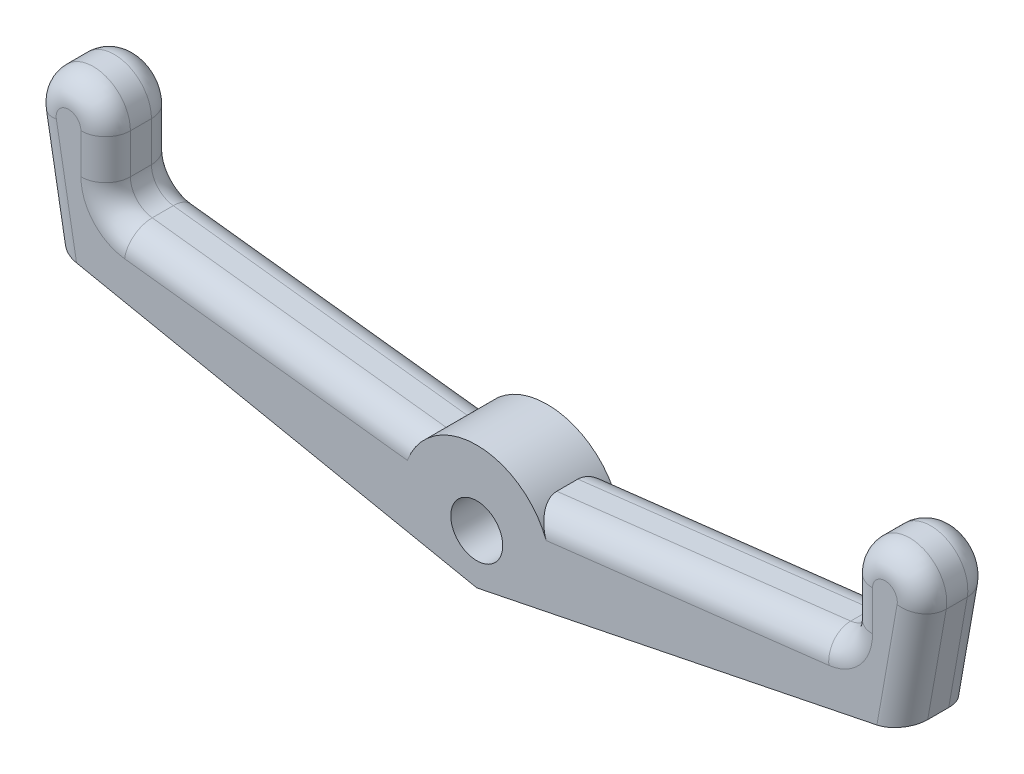
from build123d import *

# Parameters (mm, degrees)
SKETCH1_R           = 1.05
BOSS_EXTRUDE1_DEPTH = 2.85
FILLET2_R           = 1
FILLET1_R           = 1


with BuildPart() as part:
    # Sketch1 → Boss-Extrude1 (new body)
    with BuildSketch(Plane.XY):
        with BuildLine():
            Line((2.236067977, 2), (15, 3.5))
            Line((15, 3.5), (15, 6))
            ThreePointArc((15, 6), (16.630733614, 7.494292047), (17.97721163, 5.739527733))
            Line((17.97721163, 5.739527733), (17.229668505, 1.5))
            Line((17.229668505, 1.5), (0, -2))
            Line((0, -2), (-17.229668505, 1.5))
            Line((-17.229668505, 1.5), (-17.97721163, 5.739527733))
            ThreePointArc((-17.97721163, 5.739527733), (-16.630733614, 7.494292047), (-15, 6))
            Line((-15, 6), (-15, 3.5))
            Line((-15, 3.5), (-2.236067977, 2))
            ThreePointArc((-2.236067977, 2), (0, 3), (2.236067977, 2))
        make_face()
        Circle(SKETCH1_R, mode=Mode.SUBTRACT)
    extrude(amount=BOSS_EXTRUDE1_DEPTH)

    # Fillet2
    fillet2_edges = [part.edges().sort_by_distance(p)[0] for p in [
        (15, 3.5, 1.425),
        (-15, 3.5, 1.425),
    ]]
    fillet(fillet2_edges, radius=FILLET2_R)

    # Fillet1
    fillet1_edges = [part.edges().sort_by_distance(p)[0] for p in [
        (15, 5.194681496, 0),
        (16.630733614, 7.494292047, 0),
        (17.603440067, 3.619763867, 0),
        (-17.603440067, 3.619763867, 0),
        (-16.630733614, 7.494292047, 0),
        (-16.630733614, 7.494292047, 2.85),
        (-8.176391715, 2.698098798, 0),
        (-17.603440067, 3.619763867, 2.85),
        (17.603440067, 3.619763867, 2.85),
        (16.630733614, 7.494292047, 2.85),
        (15, 5.194681496, 2.85),
        (-15, 5.194681496, 0),
        (-15, 5.194681496, 2.85),
        (8.176391715, 2.698098798, 0),
        (8.176391715, 2.698098798, 2.85),
        (-14.747233381, 3.724801276, 0),
        (-14.747233381, 3.724801276, 2.85),
        (14.747233381, 3.724801276, 0),
        (14.747233381, 3.724801276, 2.85),
        (-8.176391715, 2.698098798, 2.85),
    ]]
    fillet(fillet1_edges, radius=FILLET1_R)


solid = part.part
